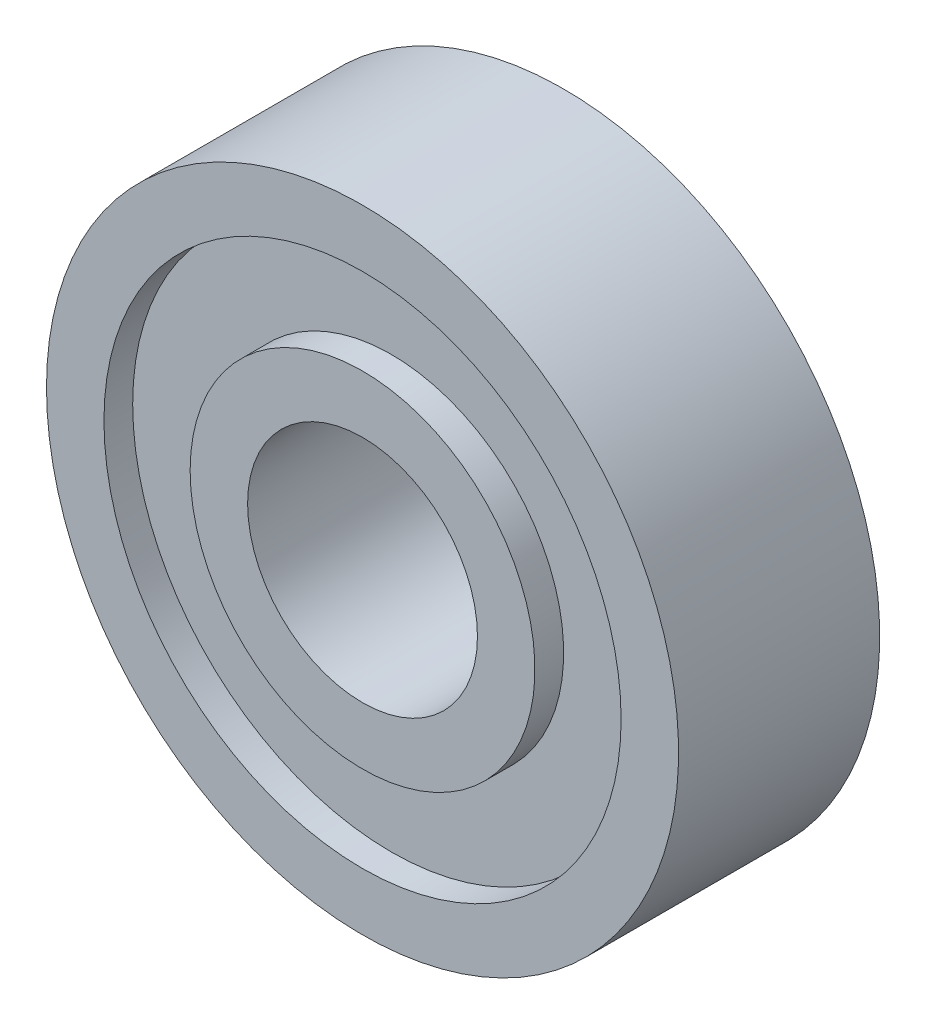
from build123d import *


with BuildPart() as part:
    # Sketch1 → Revolve1 (revolve)
    with BuildSketch(Plane.XZ):
        Polygon((6, -3.5), (6, -2.5), (9, -2.5), (9, -3.5), (11, -3.5), (11, 3.5), (9, 3.5), (9, 2.5), (6, 2.5), (6, 3.5), (4, 3.5), (4, -3.5), align=None)
    revolve(axis=Axis((0, 0, 3.5), (0, 0, -1)))


solid = part.part
